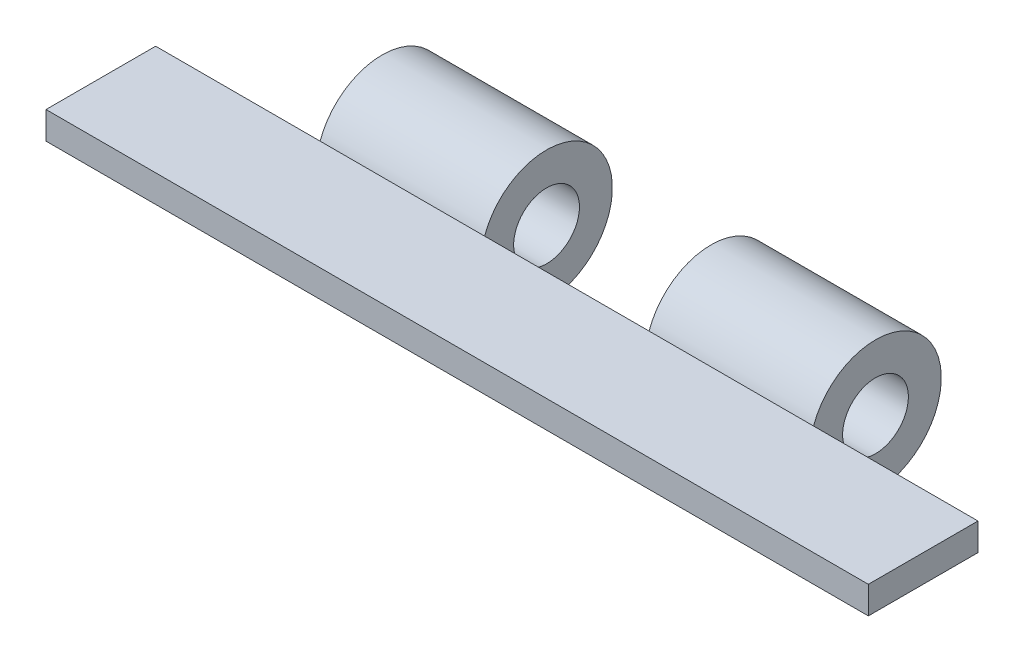
from build123d import *

# Parameters (mm, degrees)
SKETCH1_W           = 150
SKETCH1_H           = 20
BOSS_EXTRUDE1_DEPTH = 5
BOSS_EXTRUDE2_START = -60
SKETCH2_R           = 12
SKETCH2_R_2         = 6
BOSS_EXTRUDE2_DEPTH = 30
LPATTERN1_COUNT     = 2
LPATTERN1_PITCH     = 60


with BuildPart() as part:
    # Sketch1 → Boss-Extrude1 (new body)
    with BuildSketch(Plane(origin=(0, 0, 0), x_dir=(1, 0, 0), z_dir=(0, 1, 0))):
        Rectangle(SKETCH1_W, SKETCH1_H)
    extrude(amount=BOSS_EXTRUDE1_DEPTH)

    # Sketch2 → Boss-Extrude2 (add)
    with BuildSketch(Plane(origin=(75, 0, 0), x_dir=(0, 0, -1), z_dir=(1, 0, 0)).offset(BOSS_EXTRUDE2_START)):
        with Locations((21.303604064, 0.97153439)):
            Circle(SKETCH2_R)
        with Locations((21.303604064, 0.97153439)):
            Circle(SKETCH2_R_2, mode=Mode.SUBTRACT)
    boss_extrude2 = extrude(amount=BOSS_EXTRUDE2_DEPTH)

    # LPattern1: Boss-Extrude2 ×2
    with Locations(*[(-i * LPATTERN1_PITCH, 0, 0) for i in range(1, LPATTERN1_COUNT)]):
        add(boss_extrude2)


solid = part.part
